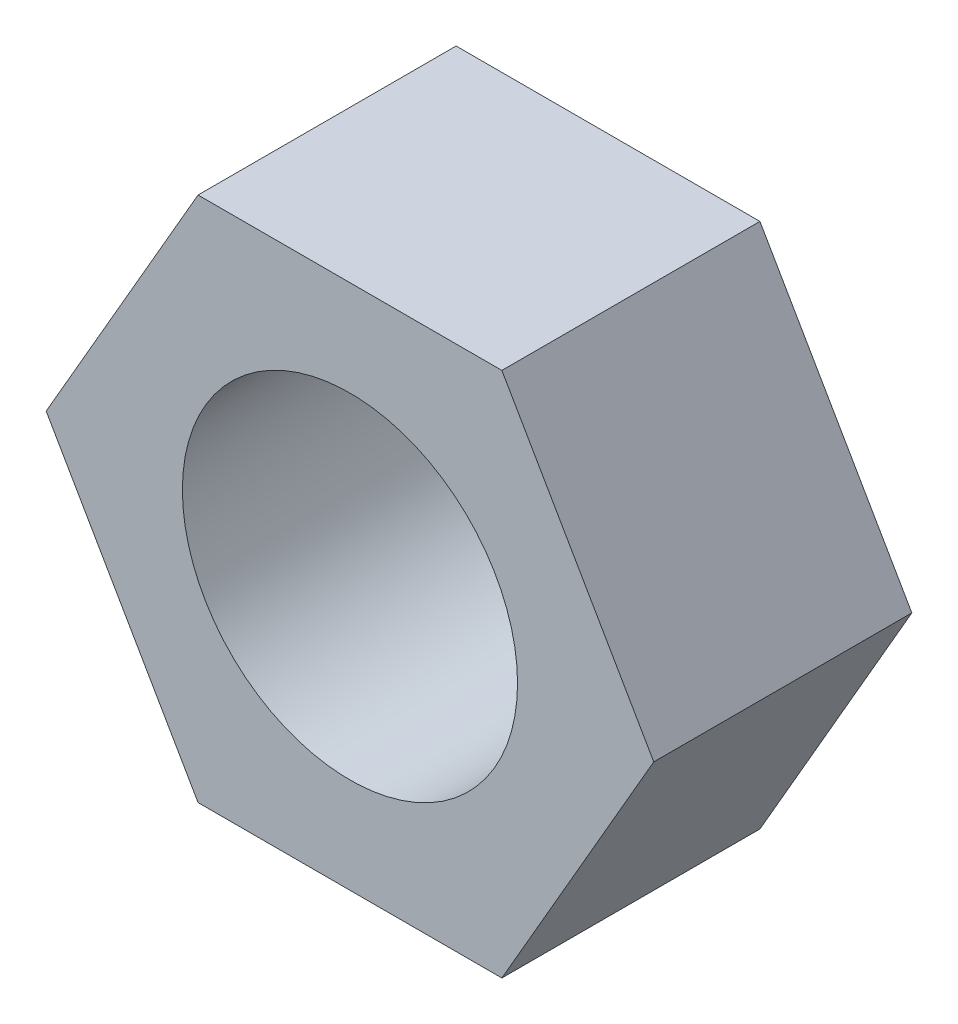
from build123d import *

# Parameters (mm, degrees)
SKETCH1_R           = 2.5
BOSS_EXTRUDE1_DEPTH = 3.85


with BuildPart() as part:
    # Sketch1 → Boss-Extrude1 (new body)
    with BuildSketch(Plane.XY):
        Polygon((4.532199613, 0), (2.266099807, 3.925), (-2.266099807, 3.925), (-4.532199613, 0), (-2.266099807, -3.925), (2.266099807, -3.925), align=None)
        Circle(SKETCH1_R, mode=Mode.SUBTRACT)
    extrude(amount=BOSS_EXTRUDE1_DEPTH)


solid = part.part
